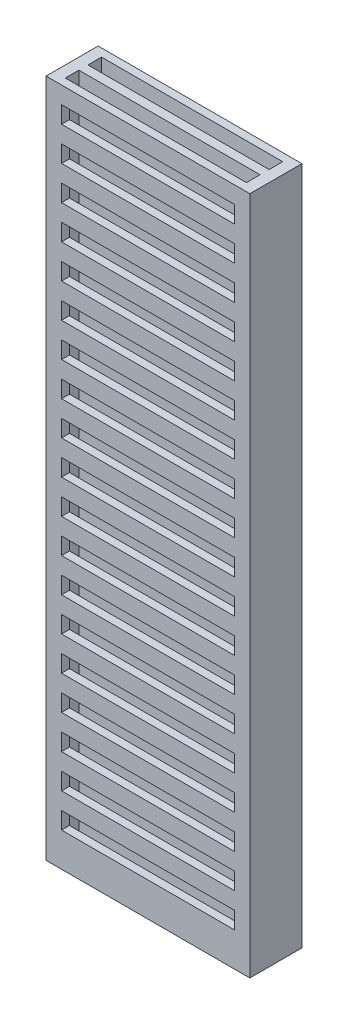
from build123d import *

# Parameters (mm, degrees)
SKETCH1_W                = 9
SKETCH1_H                = 2.3
BOSS_EXTRUDE1_DEPTH      = 15
CUT_EXTRUDE1_START       = -31
SKETCH2_W                = 8
SKETCH2_H                = 0.6
CUT_EXTRUDE1_DEPTH       = 32
SKETCH3_W                = 7.634272068
SKETCH3_H                = 0.75
CUT_EXTRUDE2_DEPTH       = 0.35
LPATTERN1_COUNT          = 19
LPATTERN1_PITCH          = 1.5
MIRROR2_COPY_1_SKETCH_W  = 7.634272068
MIRROR2_COPY_1_SKETCH_H  = 0.75
MIRROR2_COPY_1_DEPTH     = 0.35
MIRROR2_COPY_2_SKETCH_W  = 7.634272068
MIRROR2_COPY_2_SKETCH_H  = 0.75
MIRROR2_COPY_2_DEPTH     = 0.35
MIRROR2_COPY_3_SKETCH_W  = 7.634272068
MIRROR2_COPY_3_SKETCH_H  = 0.75
MIRROR2_COPY_3_DEPTH     = 0.35
MIRROR2_COPY_4_SKETCH_W  = 7.634272068
MIRROR2_COPY_4_SKETCH_H  = 0.75
MIRROR2_COPY_4_DEPTH     = 0.35
MIRROR2_COPY_5_SKETCH_W  = 7.634272068
MIRROR2_COPY_5_SKETCH_H  = 0.75
MIRROR2_COPY_5_DEPTH     = 0.35
MIRROR2_COPY_6_SKETCH_W  = 7.634272068
MIRROR2_COPY_6_SKETCH_H  = 0.75
MIRROR2_COPY_6_DEPTH     = 0.35
MIRROR2_COPY_7_SKETCH_W  = 7.634272068
MIRROR2_COPY_7_SKETCH_H  = 0.75
MIRROR2_COPY_7_DEPTH     = 0.35
MIRROR2_COPY_8_SKETCH_W  = 7.634272068
MIRROR2_COPY_8_SKETCH_H  = 0.75
MIRROR2_COPY_8_DEPTH     = 0.35
MIRROR2_COPY_9_SKETCH_W  = 7.634272068
MIRROR2_COPY_9_SKETCH_H  = 0.75
MIRROR2_COPY_9_DEPTH     = 0.35
MIRROR2_COPY_10_SKETCH_W = 7.634272068
MIRROR2_COPY_10_SKETCH_H = 0.75
MIRROR2_COPY_10_DEPTH    = 0.35
MIRROR2_COPY_11_SKETCH_W = 7.634272068
MIRROR2_COPY_11_SKETCH_H = 0.75
MIRROR2_COPY_11_DEPTH    = 0.35
MIRROR2_COPY_12_SKETCH_W = 7.634272068
MIRROR2_COPY_12_SKETCH_H = 0.75
MIRROR2_COPY_12_DEPTH    = 0.35
MIRROR2_COPY_13_SKETCH_W = 7.634272068
MIRROR2_COPY_13_SKETCH_H = 0.75
MIRROR2_COPY_13_DEPTH    = 0.35
MIRROR2_COPY_14_SKETCH_W = 7.634272068
MIRROR2_COPY_14_SKETCH_H = 0.75
MIRROR2_COPY_14_DEPTH    = 0.35
MIRROR2_COPY_15_SKETCH_W = 7.634272068
MIRROR2_COPY_15_SKETCH_H = 0.75
MIRROR2_COPY_15_DEPTH    = 0.35
MIRROR2_COPY_16_SKETCH_W = 7.634272068
MIRROR2_COPY_16_SKETCH_H = 0.75
MIRROR2_COPY_16_DEPTH    = 0.35
MIRROR2_COPY_17_SKETCH_W = 7.634272068
MIRROR2_COPY_17_SKETCH_H = 0.75
MIRROR2_COPY_17_DEPTH    = 0.35
MIRROR2_COPY_18_SKETCH_W = 7.634272068
MIRROR2_COPY_18_SKETCH_H = 0.75
MIRROR2_COPY_18_DEPTH    = 0.35


with BuildPart() as part:
    # Sketch1 → Boss-Extrude1 (new body, symmetric)
    with BuildSketch(Plane(origin=(0, 0, 0), x_dir=(1, 0, 0), z_dir=(0, 1, 0))):
        Rectangle(SKETCH1_W, SKETCH1_H)
    extrude(amount=BOSS_EXTRUDE1_DEPTH, both=True)

    # Sketch2 → Cut-Extrude1 (cut)
    with BuildSketch(Plane(origin=(0, 15, 0), x_dir=(1, 0, 0), z_dir=(0, 1, 0)).offset(CUT_EXTRUDE1_START)):
        with Locations((0, 0.5)):
            Rectangle(SKETCH2_W, SKETCH2_H)
    cut_extrude1 = extrude(amount=CUT_EXTRUDE1_DEPTH, mode=Mode.SUBTRACT)

    # Mirror1: Cut-Extrude1 across plane
    add(cut_extrude1.mirror(Plane.XY), mode=Mode.SUBTRACT)

    # Sketch3 → Cut-Extrude2 (cut)
    with BuildSketch(Plane.XY.offset(1.15)):
        with Locations((0, 13.875)):
            Rectangle(SKETCH3_W, SKETCH3_H)
    cut_extrude2 = extrude(amount=-CUT_EXTRUDE2_DEPTH, mode=Mode.SUBTRACT)

    # LPattern1: Cut-Extrude2 ×19
    with Locations(*[(0, -i * LPATTERN1_PITCH, 0) for i in range(1, LPATTERN1_COUNT)]):
        add(cut_extrude2, mode=Mode.SUBTRACT)

    # Mirror2: Cut-Extrude2 across plane
    add(cut_extrude2.mirror(Plane.XY), mode=Mode.SUBTRACT)

    # Mirror2 copy 1 sketch → Mirror2 copy 1 (cut)
    with BuildSketch(Plane(origin=(0, -1.5, -1.15), x_dir=(1, 0, 0), z_dir=(0, 0, -1))):
        with Locations((0, -13.875)):
            Rectangle(MIRROR2_COPY_1_SKETCH_W, MIRROR2_COPY_1_SKETCH_H)
    extrude(amount=-MIRROR2_COPY_1_DEPTH, mode=Mode.SUBTRACT)

    # Mirror2 copy 2 sketch → Mirror2 copy 2 (cut)
    with BuildSketch(Plane(origin=(0, -3, -1.15), x_dir=(1, 0, 0), z_dir=(0, 0, -1))):
        with Locations((0, -13.875)):
            Rectangle(MIRROR2_COPY_2_SKETCH_W, MIRROR2_COPY_2_SKETCH_H)
    extrude(amount=-MIRROR2_COPY_2_DEPTH, mode=Mode.SUBTRACT)

    # Mirror2 copy 3 sketch → Mirror2 copy 3 (cut)
    with BuildSketch(Plane(origin=(0, -4.5, -1.15), x_dir=(1, 0, 0), z_dir=(0, 0, -1))):
        with Locations((0, -13.875)):
            Rectangle(MIRROR2_COPY_3_SKETCH_W, MIRROR2_COPY_3_SKETCH_H)
    extrude(amount=-MIRROR2_COPY_3_DEPTH, mode=Mode.SUBTRACT)

    # Mirror2 copy 4 sketch → Mirror2 copy 4 (cut)
    with BuildSketch(Plane(origin=(0, -6, -1.15), x_dir=(1, 0, 0), z_dir=(0, 0, -1))):
        with Locations((0, -13.875)):
            Rectangle(MIRROR2_COPY_4_SKETCH_W, MIRROR2_COPY_4_SKETCH_H)
    extrude(amount=-MIRROR2_COPY_4_DEPTH, mode=Mode.SUBTRACT)

    # Mirror2 copy 5 sketch → Mirror2 copy 5 (cut)
    with BuildSketch(Plane(origin=(0, -7.5, -1.15), x_dir=(1, 0, 0), z_dir=(0, 0, -1))):
        with Locations((0, -13.875)):
            Rectangle(MIRROR2_COPY_5_SKETCH_W, MIRROR2_COPY_5_SKETCH_H)
    extrude(amount=-MIRROR2_COPY_5_DEPTH, mode=Mode.SUBTRACT)

    # Mirror2 copy 6 sketch → Mirror2 copy 6 (cut)
    with BuildSketch(Plane(origin=(0, -9, -1.15), x_dir=(1, 0, 0), z_dir=(0, 0, -1))):
        with Locations((0, -13.875)):
            Rectangle(MIRROR2_COPY_6_SKETCH_W, MIRROR2_COPY_6_SKETCH_H)
    extrude(amount=-MIRROR2_COPY_6_DEPTH, mode=Mode.SUBTRACT)

    # Mirror2 copy 7 sketch → Mirror2 copy 7 (cut)
    with BuildSketch(Plane(origin=(0, -10.5, -1.15), x_dir=(1, 0, 0), z_dir=(0, 0, -1))):
        with Locations((0, -13.875)):
            Rectangle(MIRROR2_COPY_7_SKETCH_W, MIRROR2_COPY_7_SKETCH_H)
    extrude(amount=-MIRROR2_COPY_7_DEPTH, mode=Mode.SUBTRACT)

    # Mirror2 copy 8 sketch → Mirror2 copy 8 (cut)
    with BuildSketch(Plane(origin=(0, -12, -1.15), x_dir=(1, 0, 0), z_dir=(0, 0, -1))):
        with Locations((0, -13.875)):
            Rectangle(MIRROR2_COPY_8_SKETCH_W, MIRROR2_COPY_8_SKETCH_H)
    extrude(amount=-MIRROR2_COPY_8_DEPTH, mode=Mode.SUBTRACT)

    # Mirror2 copy 9 sketch → Mirror2 copy 9 (cut)
    with BuildSketch(Plane(origin=(0, -13.5, -1.15), x_dir=(1, 0, 0), z_dir=(0, 0, -1))):
        with Locations((0, -13.875)):
            Rectangle(MIRROR2_COPY_9_SKETCH_W, MIRROR2_COPY_9_SKETCH_H)
    extrude(amount=-MIRROR2_COPY_9_DEPTH, mode=Mode.SUBTRACT)

    # Mirror2 copy 10 sketch → Mirror2 copy 10 (cut)
    with BuildSketch(Plane(origin=(0, -15, -1.15), x_dir=(1, 0, 0), z_dir=(0, 0, -1))):
        with Locations((0, -13.875)):
            Rectangle(MIRROR2_COPY_10_SKETCH_W, MIRROR2_COPY_10_SKETCH_H)
    extrude(amount=-MIRROR2_COPY_10_DEPTH, mode=Mode.SUBTRACT)

    # Mirror2 copy 11 sketch → Mirror2 copy 11 (cut)
    with BuildSketch(Plane(origin=(0, -16.5, -1.15), x_dir=(1, 0, 0), z_dir=(0, 0, -1))):
        with Locations((0, -13.875)):
            Rectangle(MIRROR2_COPY_11_SKETCH_W, MIRROR2_COPY_11_SKETCH_H)
    extrude(amount=-MIRROR2_COPY_11_DEPTH, mode=Mode.SUBTRACT)

    # Mirror2 copy 12 sketch → Mirror2 copy 12 (cut)
    with BuildSketch(Plane(origin=(0, -18, -1.15), x_dir=(1, 0, 0), z_dir=(0, 0, -1))):
        with Locations((0, -13.875)):
            Rectangle(MIRROR2_COPY_12_SKETCH_W, MIRROR2_COPY_12_SKETCH_H)
    extrude(amount=-MIRROR2_COPY_12_DEPTH, mode=Mode.SUBTRACT)

    # Mirror2 copy 13 sketch → Mirror2 copy 13 (cut)
    with BuildSketch(Plane(origin=(0, -19.5, -1.15), x_dir=(1, 0, 0), z_dir=(0, 0, -1))):
        with Locations((0, -13.875)):
            Rectangle(MIRROR2_COPY_13_SKETCH_W, MIRROR2_COPY_13_SKETCH_H)
    extrude(amount=-MIRROR2_COPY_13_DEPTH, mode=Mode.SUBTRACT)

    # Mirror2 copy 14 sketch → Mirror2 copy 14 (cut)
    with BuildSketch(Plane(origin=(0, -21, -1.15), x_dir=(1, 0, 0), z_dir=(0, 0, -1))):
        with Locations((0, -13.875)):
            Rectangle(MIRROR2_COPY_14_SKETCH_W, MIRROR2_COPY_14_SKETCH_H)
    extrude(amount=-MIRROR2_COPY_14_DEPTH, mode=Mode.SUBTRACT)

    # Mirror2 copy 15 sketch → Mirror2 copy 15 (cut)
    with BuildSketch(Plane(origin=(0, -22.5, -1.15), x_dir=(1, 0, 0), z_dir=(0, 0, -1))):
        with Locations((0, -13.875)):
            Rectangle(MIRROR2_COPY_15_SKETCH_W, MIRROR2_COPY_15_SKETCH_H)
    extrude(amount=-MIRROR2_COPY_15_DEPTH, mode=Mode.SUBTRACT)

    # Mirror2 copy 16 sketch → Mirror2 copy 16 (cut)
    with BuildSketch(Plane(origin=(0, -24, -1.15), x_dir=(1, 0, 0), z_dir=(0, 0, -1))):
        with Locations((0, -13.875)):
            Rectangle(MIRROR2_COPY_16_SKETCH_W, MIRROR2_COPY_16_SKETCH_H)
    extrude(amount=-MIRROR2_COPY_16_DEPTH, mode=Mode.SUBTRACT)

    # Mirror2 copy 17 sketch → Mirror2 copy 17 (cut)
    with BuildSketch(Plane(origin=(0, -25.5, -1.15), x_dir=(1, 0, 0), z_dir=(0, 0, -1))):
        with Locations((0, -13.875)):
            Rectangle(MIRROR2_COPY_17_SKETCH_W, MIRROR2_COPY_17_SKETCH_H)
    extrude(amount=-MIRROR2_COPY_17_DEPTH, mode=Mode.SUBTRACT)

    # Mirror2 copy 18 sketch → Mirror2 copy 18 (cut)
    with BuildSketch(Plane(origin=(0, -27, -1.15), x_dir=(1, 0, 0), z_dir=(0, 0, -1))):
        with Locations((0, -13.875)):
            Rectangle(MIRROR2_COPY_18_SKETCH_W, MIRROR2_COPY_18_SKETCH_H)
    extrude(amount=-MIRROR2_COPY_18_DEPTH, mode=Mode.SUBTRACT)


solid = part.part
